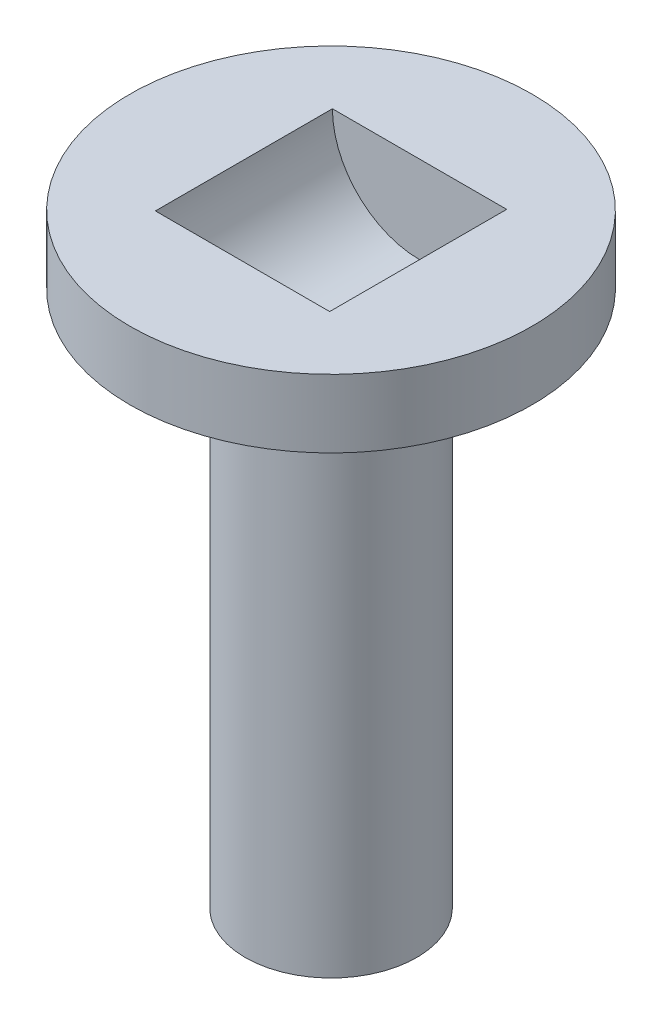
from build123d import *

# Parameters (mm, degrees)
SKETCH1_R               = 3.2
BOSS_EXTRUDE1_DEPTH     = 20
SKETCH2_R               = 1.1
CUT_EXTRUDE1_DEPTH      = 10
SKETCH4_R               = 7.5
BOSS_EXTRUDE2_DEPTH     = 2.54
SKETCH6_R               = 4.85
BOSS_EXTRUDE3_DEPTH     = 3.35
SKETCH5_R               = 3.25
CUT_EXTRUDE3_DEPTH      = 3.3
CUT_EXTRUDE3_DEPTH_BACK = 3.302


with BuildPart() as part:
    # Sketch1 → Boss-Extrude1 (new body)
    with BuildSketch(Plane(origin=(0, 0, 0), x_dir=(1, 0, 0), z_dir=(0, 1, 0))):
        Circle(SKETCH1_R)
    extrude(amount=BOSS_EXTRUDE1_DEPTH)

    # Sketch2 → Cut-Extrude1 (cut)
    with BuildSketch(Plane.XZ):
        Circle(SKETCH2_R)
    extrude(amount=-CUT_EXTRUDE1_DEPTH, mode=Mode.SUBTRACT)

    # Sketch4 → Boss-Extrude2 (add)
    with BuildSketch(Plane(origin=(0, 20, 0), x_dir=(1, 0, 0), z_dir=(0, 1, 0))):
        Circle(SKETCH4_R)
    extrude(amount=BOSS_EXTRUDE2_DEPTH)

    # Sketch6 → Boss-Extrude3 (add)
    with BuildSketch(Plane(origin=(0, 22.54, 0), x_dir=(1, 0, 0), z_dir=(0, 1, 0))):
        Circle(SKETCH6_R)
    extrude(amount=-BOSS_EXTRUDE3_DEPTH)

    # Sketch5 → Cut-Extrude3 (cut, two sides)
    with BuildSketch(Plane.XY) as cut_extrude3_sk:
        with Locations((0, 22.54)):
            Circle(SKETCH5_R)
    extrude(amount=CUT_EXTRUDE3_DEPTH, mode=Mode.SUBTRACT)
    extrude(cut_extrude3_sk.sketch, amount=-CUT_EXTRUDE3_DEPTH_BACK, mode=Mode.SUBTRACT)


solid = part.part
